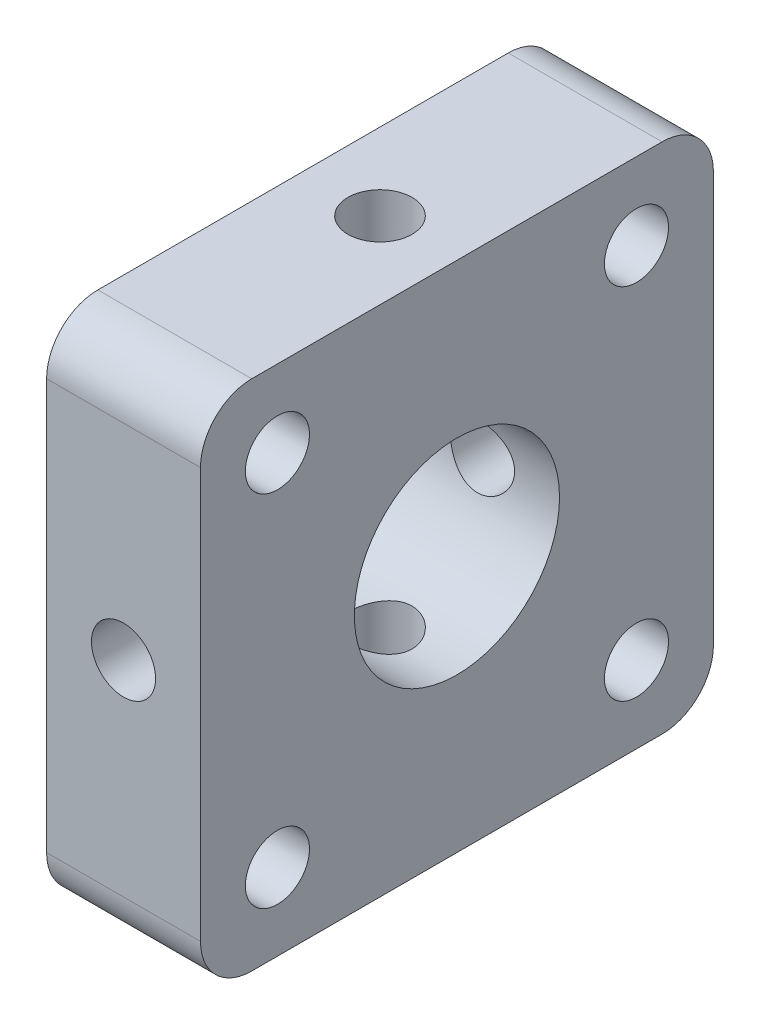
from build123d import *

# Parameters (mm, degrees)
SKETCH_3_W          = 20
SKETCH_3_H          = 20
SKETCH_3_R          = 4
EXTRUDE_2_DEPTH     = 6
SKETCH_4_R          = 1
CUT_EXTRUDE_1_DEPTH = 6
HOLE_WIZARD_M3_1_D  = 2.5
HOLE_WIZARD_M3_2_D  = 2.5
FILLET_1_R          = 2
HOLE_WIZARD_M3_3_D  = 2.5


with BuildPart() as part:
    # 草图3 → 凸台-拉伸2 (new body)
    with BuildSketch(Plane(origin=(0, 0, 0), x_dir=(0, 0, -1), z_dir=(1, 0, 0))):
        Rectangle(SKETCH_3_W, SKETCH_3_H)
        Circle(SKETCH_3_R, mode=Mode.SUBTRACT)
    extrude(amount=EXTRUDE_2_DEPTH)

    # 草图4 → 切除-拉伸1 (cut)
    with BuildSketch(Plane(origin=(6, 0, 0), x_dir=(0, 0, -1), z_dir=(1, 0, 0))):
        with Locations((-7, 7)):
            Circle(SKETCH_4_R)
        with Locations((7, 7)):
            Circle(SKETCH_4_R)
        with Locations((-7, -7)):
            Circle(SKETCH_4_R)
        with Locations((7, -7)):
            Circle(SKETCH_4_R)
    extrude(amount=-CUT_EXTRUDE_1_DEPTH, mode=Mode.SUBTRACT)

    # M3 螺纹孔1 (through all)
    with Locations(Plane(origin=(0, 10, 0), x_dir=(1, 0, 0), z_dir=(0, 1, 0))):
        with Locations((3, 0)):
            Hole(HOLE_WIZARD_M3_1_D / 2)

    # M3 螺纹孔2 (through all)
    with Locations(Plane(origin=(0, 0, -10), x_dir=(-1, 0, 0), z_dir=(0, 0, -1))):
        with Locations((-3, 0)):
            Hole(HOLE_WIZARD_M3_2_D / 2)

    # 圆角1
    fillet_1_edges = [part.edges().sort_by_distance(p)[0] for p in [
        (3, 10, 10),
        (3, 10, -10),
        (3, -10, -10),
        (3, -10, 10),
    ]]
    fillet(fillet_1_edges, radius=FILLET_1_R)

    # M3 螺纹孔3 (through all)
    with Locations(Plane.ZY):
        with Locations((-7, 7), (7, 7), (-7, -7), (7, -7)):
            Hole(HOLE_WIZARD_M3_3_D / 2)


solid = part.part
